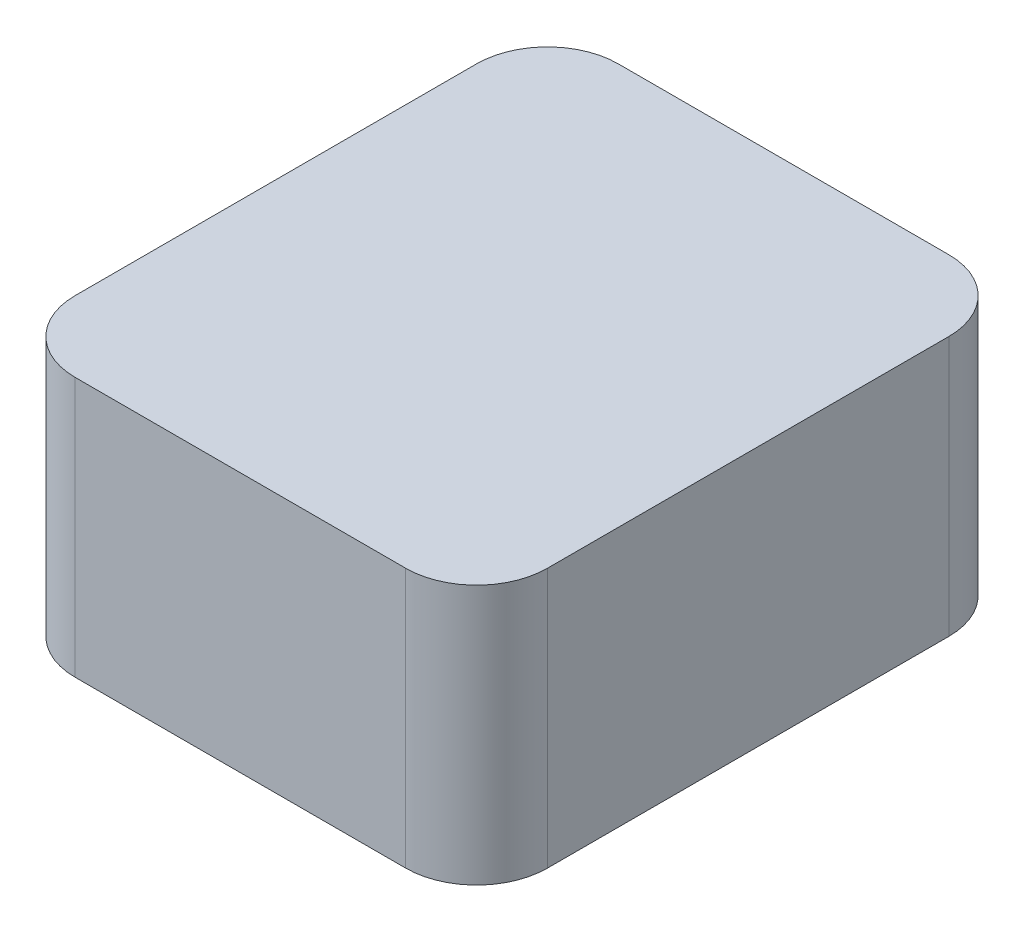
from build123d import *

# Parameters (mm, degrees)
SKETCH1_W           = 20
SKETCH1_H           = 23
BOSS_EXTRUDE1_DEPTH = 11
FILLET1_R           = 3


with BuildPart() as part:
    # Sketch1 → Boss-Extrude1 (new body)
    with BuildSketch(Plane(origin=(0, 0, 0), x_dir=(1, 0, 0), z_dir=(0, 1, 0))):
        with Locations((10, 11.5)):
            Rectangle(SKETCH1_W, SKETCH1_H)
    extrude(amount=BOSS_EXTRUDE1_DEPTH)

    # Fillet1
    fillet1_edges = [part.edges().sort_by_distance(p)[0] for p in [
        (0, 5.5, -23),
        (20, 5.5, -23),
        (20, 5.5, 0),
        (0, 5.5, 0),
    ]]
    fillet(fillet1_edges, radius=FILLET1_R)


solid = part.part
